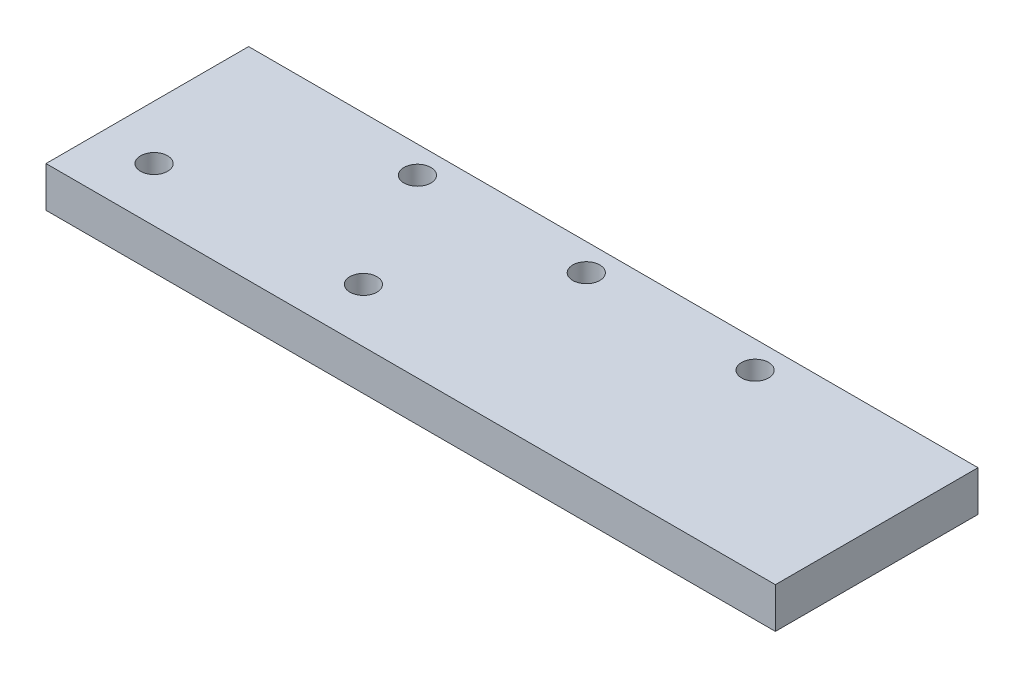
from build123d import *

# Parameters (mm, degrees)
SKETCH1_W           = 108
SKETCH1_H           = 30
BOSS_EXTRUDE1_DEPTH = 6
SKETCH2_R           = 2
CUT_EXTRUDE1_DEPTH  = 10


with BuildPart() as part:
    # Sketch1 → Boss-Extrude1 (new body)
    with BuildSketch(Plane(origin=(0, 0, 0), x_dir=(1, 0, 0), z_dir=(0, 1, 0))):
        with Locations((-48.510460251, 50.167364017)):
            Rectangle(SKETCH1_W, SKETCH1_H)
    extrude(amount=BOSS_EXTRUDE1_DEPTH)

    # Sketch2 → Cut-Extrude1 (cut)
    with BuildSketch(Plane.XZ):
        with Locations((-73.510460251, -61.167364017)):
            Circle(SKETCH2_R)
        with Locations((-48.510460251, -61.167364017)):
            Circle(SKETCH2_R)
        with Locations((-23.510460251, -61.167364017)):
            Circle(SKETCH2_R)
        with Locations((-94.510460251, -43.167364017)):
            Circle(SKETCH2_R)
        with Locations((-63.510460251, -43.167364017)):
            Circle(SKETCH2_R)
    extrude(amount=-CUT_EXTRUDE1_DEPTH, mode=Mode.SUBTRACT)


solid = part.part
